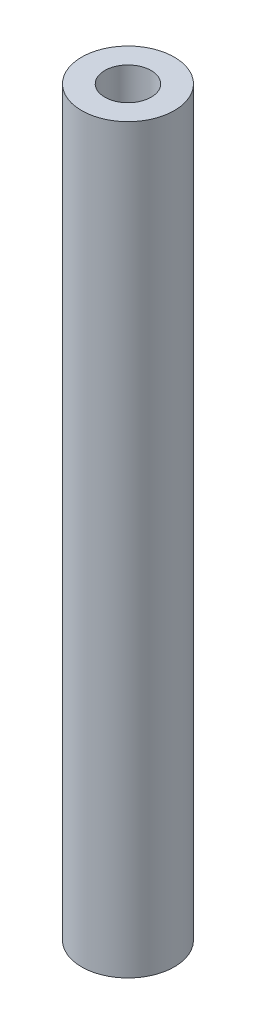
from build123d import *

# Parameters (mm, degrees)
SKETCH1_R           = 5
SKETCH1_R_2         = 2.5
BOSS_EXTRUDE1_DEPTH = 80


with BuildPart() as part:
    # Sketch1 → Boss-Extrude1 (new body)
    with BuildSketch(Plane(origin=(0, 0, 0), x_dir=(1, 0, 0), z_dir=(0, 1, 0))):
        Circle(SKETCH1_R)
        Circle(SKETCH1_R_2, mode=Mode.SUBTRACT)
    extrude(amount=BOSS_EXTRUDE1_DEPTH)


solid = part.part
